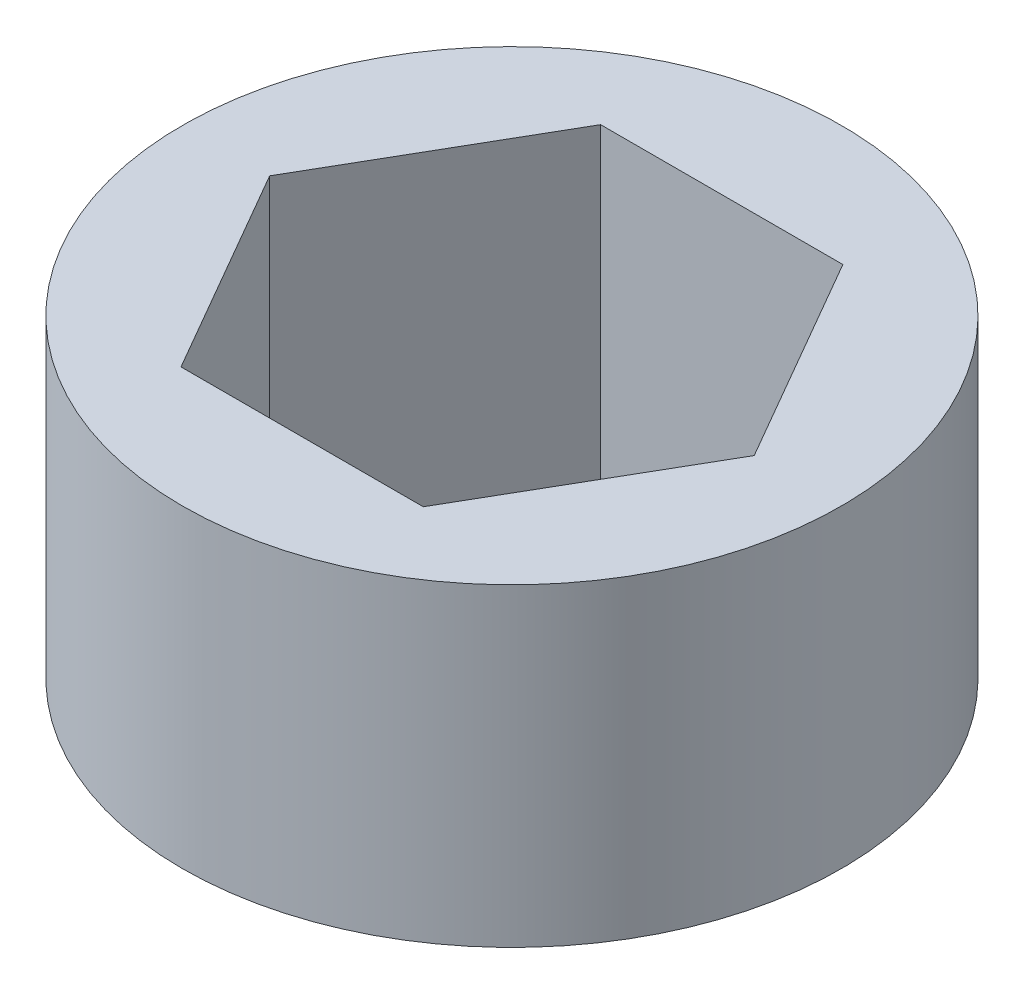
from build123d import *

# Parameters (mm, degrees)
SKETCH1_R           = 9.9949
BOSS_EXTRUDE1_DEPTH = 9.525


with BuildPart() as part:
    # Sketch1 → Boss-Extrude1 (new body)
    with BuildSketch(Plane(origin=(0, 0, 0), x_dir=(1, 0, 0), z_dir=(0, 1, 0))):
        Circle(SKETCH1_R)
        Polygon((7.347013116, 0), (3.673506558, 6.3627), (-3.673506558, 6.3627), (-7.347013116, 0), (-3.673506558, -6.3627), (3.673506558, -6.3627), align=None, mode=Mode.SUBTRACT)
    extrude(amount=BOSS_EXTRUDE1_DEPTH)


solid = part.part
